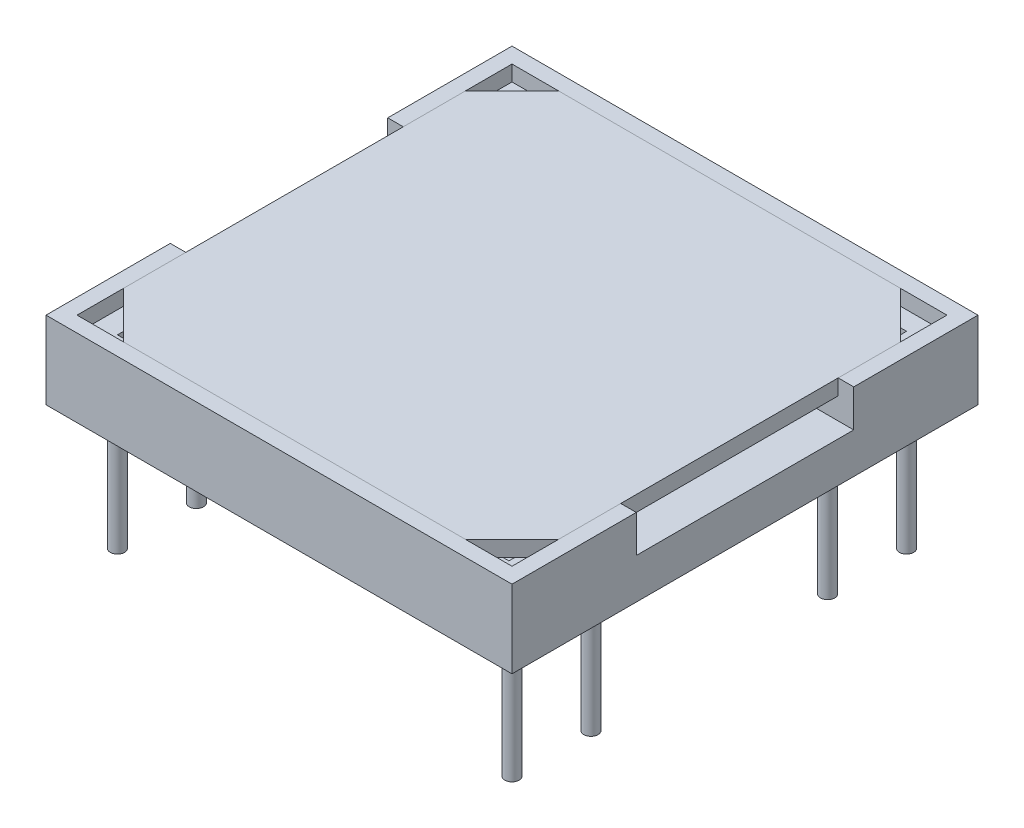
from build123d import *

# Parameters (mm, degrees)
SKETCH1_W           = 15
SKETCH1_H           = 15
BOSS_EXTRUDE1_DEPTH = 0.61
BOSS_EXTRUDE2_START = 0.61
SKETCH1_3_W         = 5.85
SKETCH1_3_H         = 5.95
BOSS_EXTRUDE2_DEPTH = 0.69
BOSS_EXTRUDE3_START = 0.61
SKETCH1_4_W         = 0.5
SKETCH1_4_H         = 7
BOSS_EXTRUDE3_DEPTH = 1.39
BOSS_EXTRUDE4_START = 2
SKETCH1_7_W         = 0.5
SKETCH1_7_H         = 7
BOSS_EXTRUDE4_DEPTH = 0.5
CUT_EXTRUDE1_START  = 1.3
SKETCH1_6_W         = 0.5
SKETCH1_6_H         = 7
CUT_EXTRUDE1_DEPTH  = 1.2
SKETCH2_R           = 0.23
BOSS_EXTRUDE5_DEPTH = 3.999992
BOSS_EXTRUDE6_DEPTH = 0.5


with BuildPart() as part:
    # Sketch1 → Boss-Extrude1 (new body)
    with BuildSketch(Plane(origin=(0, 0, 0), x_dir=(1, 0, 0), z_dir=(0, 1, 0))):
        Rectangle(SKETCH1_W, SKETCH1_H)
    extrude(amount=BOSS_EXTRUDE1_DEPTH)

    # Sketch1_3 → Boss-Extrude2 (add)
    with BuildSketch(Plane(origin=(0, 0, 0), x_dir=(1, 0, 0), z_dir=(0, 1, 0)).offset(BOSS_EXTRUDE2_START)):
        with Locations((-3.175, 3.225)):
            Rectangle(SKETCH1_3_W, SKETCH1_3_H)
        with Locations((-3.175, -3.225)):
            Rectangle(SKETCH1_3_W, SKETCH1_3_H)
        with Locations((3.175, -3.225)):
            Rectangle(SKETCH1_3_W, SKETCH1_3_H)
        with Locations((3.175, 3.225)):
            Rectangle(SKETCH1_3_W, SKETCH1_3_H)
    extrude(amount=BOSS_EXTRUDE2_DEPTH)

    # Sketch1_4 → Boss-Extrude3 (add)
    with BuildSketch(Plane(origin=(0, 0, 0), x_dir=(1, 0, 0), z_dir=(0, 1, 0)).offset(BOSS_EXTRUDE3_START)):
        Polygon((-7.5, 7.5), (-7.5, 3.5), (-7, 3.5), (-7, 7), (7, 7), (7, 3.5), (7.5, 3.5), (7.5, 7.5), align=None)
        Polygon((-7, 7), (-7, 3.5), (-6.3, 3.5), (-6.3, 6.4), (-0.05, 6.4), (0.05, 6.4), (6.3, 6.4), (6.3, 3.5), (7, 3.5), (7, 7), align=None)
        with Locations((-7.25, 0)):
            Rectangle(SKETCH1_4_W, SKETCH1_4_H)
        Polygon((-7, 3.5), (-7, -3.5), (-6.3, -3.5), (-6.3, -0.05), (-6.3, 0.05), (-6.3, 3.5), align=None)
        Polygon((-7.5, -3.5), (-7.5, -7.5), (7.5, -7.5), (7.5, -3.5), (7, -3.5), (7, -7), (-7, -7), (-7, -3.5), align=None)
        Polygon((-6.3, -3.5), (-7, -3.5), (-7, -7), (7, -7), (7, -3.5), (6.3, -3.5), (6.3, -6.4), (0.05, -6.4), (-0.05, -6.4), (-6.3, -6.4), align=None)
        Polygon((6.3, -3.5), (7, -3.5), (7, 3.5), (6.3, 3.5), (6.3, 0.05), (6.3, -0.05), align=None)
        with Locations((7.25, 0)):
            Rectangle(SKETCH1_4_W, SKETCH1_4_H)
    extrude(amount=BOSS_EXTRUDE3_DEPTH)

    # Sketch1_7 → Boss-Extrude4 (add)
    with BuildSketch(Plane(origin=(0, 0, 0), x_dir=(1, 0, 0), z_dir=(0, 1, 0)).offset(BOSS_EXTRUDE4_START)):
        Polygon((-7.5, 7.5), (-7.5, 3.5), (-7, 3.5), (-7, 7), (7, 7), (7, 3.5), (7.5, 3.5), (7.5, 7.5), align=None)
        with Locations((-7.25, 0)):
            Rectangle(SKETCH1_7_W, SKETCH1_7_H)
        Polygon((-7.5, -3.5), (-7.5, -7.5), (7.5, -7.5), (7.5, -3.5), (7, -3.5), (7, -7), (-7, -7), (-7, -3.5), align=None)
        with Locations((7.25, 0)):
            Rectangle(SKETCH1_7_W, SKETCH1_7_H)
    extrude(amount=BOSS_EXTRUDE4_DEPTH)

    # Sketch1_6 → Cut-Extrude1 (cut)
    with BuildSketch(Plane(origin=(0, 0, 0), x_dir=(1, 0, 0), z_dir=(0, 1, 0)).offset(CUT_EXTRUDE1_START)):
        with Locations((-7.25, 0)):
            Rectangle(SKETCH1_6_W, SKETCH1_6_H)
        with Locations((7.25, 0)):
            Rectangle(SKETCH1_6_W, SKETCH1_6_H)
        Polygon((-7, 3.5), (-7, -3.5), (-6.3, -3.5), (-6.3, -0.05), (-6.3, 0.05), (-6.3, 3.5), align=None)
        Polygon((6.3, -3.5), (7, -3.5), (7, 3.5), (6.3, 3.5), (6.3, 0.05), (6.3, -0.05), align=None)
    extrude(amount=CUT_EXTRUDE1_DEPTH, mode=Mode.SUBTRACT)

    # Sketch2 → Boss-Extrude5 (add)
    with BuildSketch(Plane.XZ):
        with Locations((6.35, 6.35)):
            Circle(SKETCH2_R)
        with Locations((6.35, 3.81)):
            Circle(SKETCH2_R)
        with Locations((-6.35, 3.81)):
            Circle(SKETCH2_R)
        with Locations((-6.35, 6.35)):
            Circle(SKETCH2_R)
        with Locations((6.35, -3.81)):
            Circle(SKETCH2_R)
        with Locations((6.35, -6.35)):
            Circle(SKETCH2_R)
        with Locations((-6.35, -6.35)):
            Circle(SKETCH2_R)
        with Locations((-6.35, -3.81)):
            Circle(SKETCH2_R)
    extrude(amount=BOSS_EXTRUDE5_DEPTH)


with BuildPart() as body_2:
    # Sketch3 → Boss-Extrude6 (new body)
    with BuildSketch(Plane(origin=(0, 2, 0), x_dir=(1, 0, 0), z_dir=(0, 1, 0))):
        Polygon((6.3, -6.199999978), (7, -5.5), (7, -3.5), (6.3, -3.5), align=None)
        Polygon((6.099999971, -6.4), (6.3, -6.199999978), (6.3, -3.5), (7, -3.5), (7, 5.5), (5.499999952, 7), (-5.499999952, 7), (-7, 5.5), (-7, -3.5), (-6.3, -3.5), (-6.3, -6.199999978), (-6.099999971, -6.4), align=None)
        Polygon((5.499999952, -7), (6.099999971, -6.4), (-6.099999971, -6.4), (-5.499999952, -7), align=None)
        Polygon((-7, -5.5), (-6.3, -6.199999978), (-6.3, -3.5), (-7, -3.5), align=None)
    extrude(amount=BOSS_EXTRUDE6_DEPTH)


solid = Compound([part.part, body_2.part])
